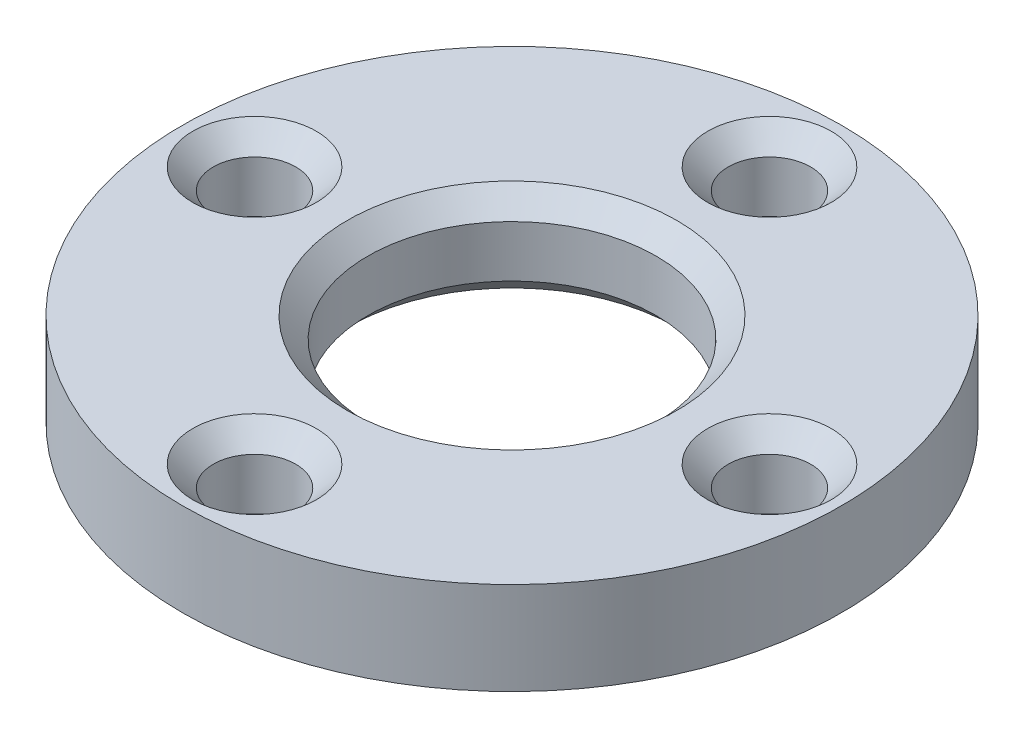
from build123d import *

# Parameters (mm, degrees)
SKETCH1_R           = 16
SKETCH1_R_2         = 7
SKETCH1_R_3         = 2
BOSS_EXTRUDE1_DEPTH = 4.5
CHAMFER1_SIZE       = 1


with BuildPart() as part:
    # Sketch1 → Boss-Extrude1 (new body)
    with BuildSketch(Plane(origin=(0, 0, 0), x_dir=(1, 0, 0), z_dir=(0, 1, 0))):
        Circle(SKETCH1_R)
        Circle(SKETCH1_R_2, mode=Mode.SUBTRACT)
        with Locations((0, 12.5)):
            Circle(SKETCH1_R_3, mode=Mode.SUBTRACT)
        with Locations((12.5, 0)):
            Circle(SKETCH1_R_3, mode=Mode.SUBTRACT)
        with Locations((0, -12.5)):
            Circle(SKETCH1_R_3, mode=Mode.SUBTRACT)
        with Locations((-12.5, 0)):
            Circle(SKETCH1_R_3, mode=Mode.SUBTRACT)
    extrude(amount=BOSS_EXTRUDE1_DEPTH)

    # Chamfer1
    chamfer1_edges = [part.edges().sort_by_distance(p)[0] for p in [
        (10.5, 0, 0),
        (10.5, 4.5, 0),
        (-2, 0, 12.5),
        (-2, 4.5, 12.5),
        (-14.5, 0, 0),
        (-14.5, 4.5, 0),
        (-7, 0, 0),
        (-7, 4.5, 0),
        (-2, 0, -12.5),
        (-2, 4.5, -12.5),
    ]]
    chamfer(chamfer1_edges, length=CHAMFER1_SIZE)


solid = part.part
